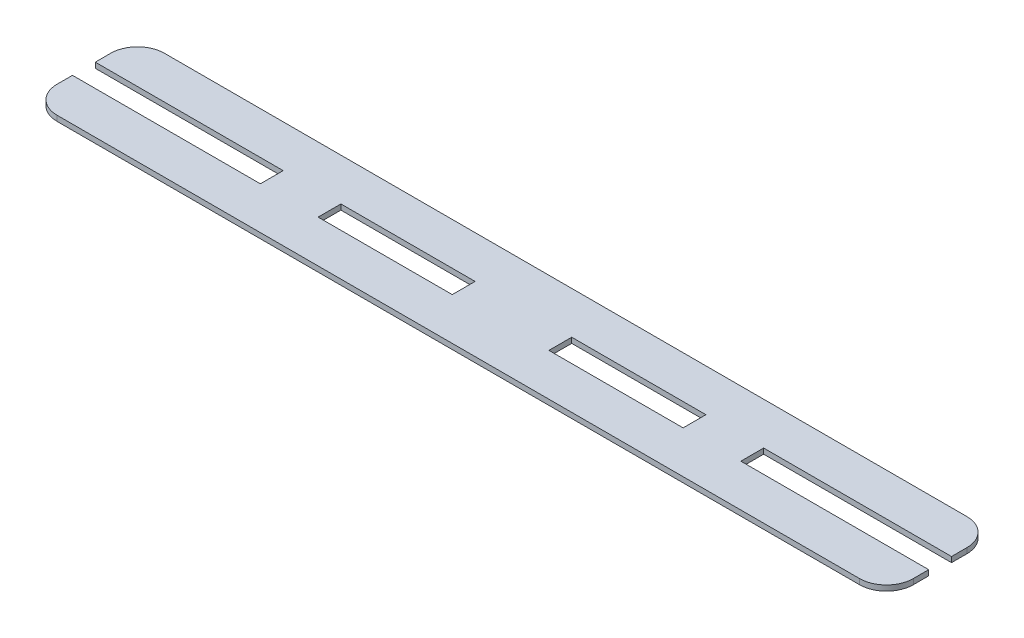
from build123d import *

# Parameters (mm, degrees)
SKETCH1_W           = 319
SKETCH1_H           = 40
BOSS_EXTRUDE1_DEPTH = 2
SKETCH2_W           = 70
SKETCH2_H           = 8.5
CUT_EXTRUDE1_DEPTH  = 3
SKETCH3_W           = 50
SKETCH3_H           = 8.5
CUT_EXTRUDE2_DEPTH  = 3
FILLET1_R           = 10


with BuildPart() as part:
    # Sketch1 → Boss-Extrude1 (new body)
    with BuildSketch(Plane(origin=(0, 0, 0), x_dir=(1, 0, 0), z_dir=(0, 1, 0))):
        with Locations((159.5, -20)):
            Rectangle(SKETCH1_W, SKETCH1_H)
    extrude(amount=BOSS_EXTRUDE1_DEPTH)

    # Sketch2 → Cut-Extrude1 (cut, through all)
    with BuildSketch(Plane(origin=(0, 2, 0), x_dir=(1, 0, 0), z_dir=(0, 1, 0))):
        with Locations((35, -20)):
            Rectangle(SKETCH2_W, SKETCH2_H)
    cut_extrude1 = extrude(amount=-CUT_EXTRUDE1_DEPTH, mode=Mode.SUBTRACT)

    # Sketch3 → Cut-Extrude2 (cut, through all)
    with BuildSketch(Plane(origin=(0, 2, 0), x_dir=(1, 0, 0), z_dir=(0, 1, 0))):
        with Locations((116.5, -20)):
            Rectangle(SKETCH3_W, SKETCH3_H)
    cut_extrude2 = extrude(amount=-CUT_EXTRUDE2_DEPTH, mode=Mode.SUBTRACT)

    # Mirror1: Cut-Extrude1, Cut-Extrude2 across plane
    add(cut_extrude1.mirror(Plane.ZY.offset(-159.5)), mode=Mode.SUBTRACT)
    add(cut_extrude2.mirror(Plane.ZY.offset(-159.5)), mode=Mode.SUBTRACT)

    # Fillet1
    fillet1_edges = [part.edges().sort_by_distance(p)[0] for p in [
        (0, 1, 0),
        (319, 1, 0),
        (319, 1, 40),
        (0, 1, 40),
    ]]
    fillet(fillet1_edges, radius=FILLET1_R)


solid = part.part
